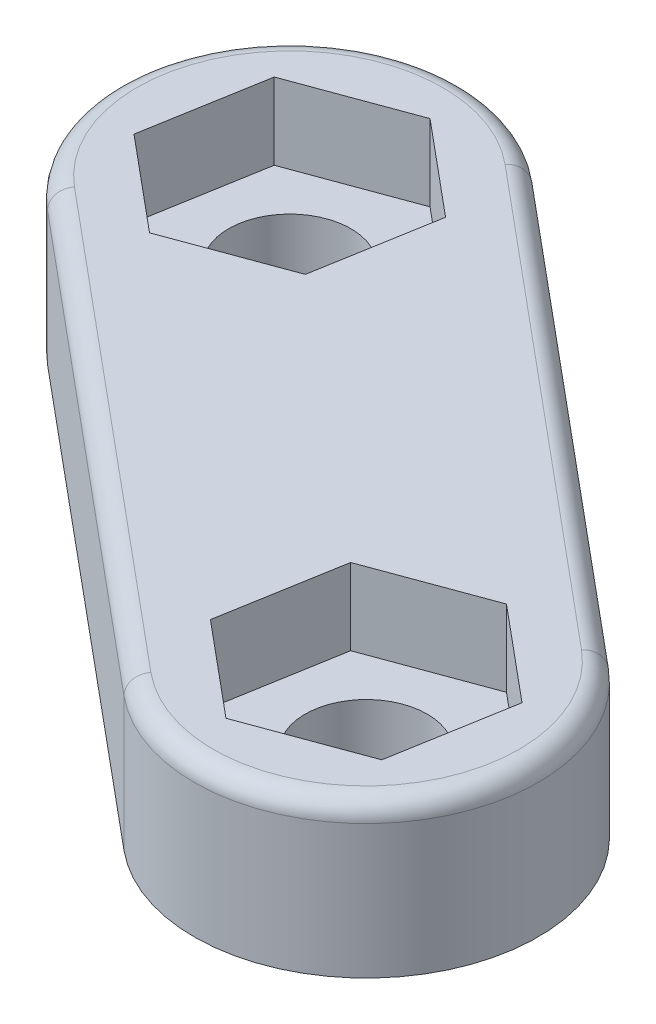
from build123d import *

# Parameters (mm, degrees)
BOSS_EXTRUDE1_DEPTH = 4
CUT_EXTRUDE1_DEPTH  = 2
FILLET1_R           = 0.5


with BuildPart() as part:
    # Sketch1 → Boss-Extrude1 (new body)
    with BuildSketch(Plane(origin=(0, 0, 0), x_dir=(1, 0, 0), z_dir=(0, 1, 0))):
        with BuildLine():
            ThreePointArc((-3.119170202, 8.456995758), (-9.456995758, 7.880829798), (-8.880829798, 1.543004242))
            ThreePointArc((-8.880829798, 1.543004242), (-7.531913687, 0.7687779), (-6, 0.5))
            Line((-6, 0.5), (-6, 3.4))
            ThreePointArc((-6, 3.4), (-7.13137085, 6.13137085), (-4.4, 5))
            Line((-4.4, 5), (-1.5, 5))
            ThreePointArc((-1.5, 5), (-1.924847604, 6.908699283), (-3.119170202, 8.456995758))
        make_face()
        with BuildLine():
            Line((-6, 3.4), (-6, 0.5))
            ThreePointArc((-6, 0.5), (-2.818019485, 1.818019485), (-1.5, 5))
            Line((-1.5, 5), (-4.4, 5))
            ThreePointArc((-4.4, 5), (-4.86862915, 3.86862915), (-6, 3.4))
        make_face()
        with BuildLine():
            Line((-6, 0.5), (-6, -0.857687257))
            Line((-6, -0.857687257), (-1.029224708, -5))
            Line((-1.029224708, -5), (1.5, -5))
            ThreePointArc((1.5, -5), (2.818019485, -1.818019485), (6, -0.5))
            Line((6, -0.5), (6, 0.857687257))
            Line((6, 0.857687257), (1.029224708, 5))
            Line((1.029224708, 5), (-1.5, 5))
            ThreePointArc((-1.5, 5), (-2.818019485, 1.818019485), (-6, 0.5))
        make_face()
        with BuildLine():
            ThreePointArc((1.5, -5), (1.924847604, -6.908699283), (3.119170202, -8.456995758))
            ThreePointArc((3.119170202, -8.456995758), (7.908699283, -9.075152396), (10.5, -5))
            ThreePointArc((10.5, -5), (10.075152396, -3.091300717), (8.880829798, -1.543004242))
            ThreePointArc((8.880829798, -1.543004242), (7.531913687, -0.7687779), (6, -0.5))
            Line((6, -0.5), (6, -3.4))
            ThreePointArc((6, -3.4), (7.13137085, -3.86862915), (7.6, -5))
            ThreePointArc((7.6, -5), (6, -6.6), (4.4, -5))
            Line((4.4, -5), (1.5, -5))
        make_face()
        with BuildLine():
            ThreePointArc((6, -0.5), (2.818019485, -1.818019485), (1.5, -5))
            Line((1.5, -5), (4.4, -5))
            ThreePointArc((4.4, -5), (4.86862915, -3.86862915), (6, -3.4))
            Line((6, -3.4), (6, -0.5))
        make_face()
        with BuildLine():
            Line((1.5, -5), (-1.029224708, -5))
            Line((-1.029224708, -5), (3.119170202, -8.456995758))
            ThreePointArc((3.119170202, -8.456995758), (1.924847604, -6.908699283), (1.5, -5))
        make_face()
        with BuildLine():
            ThreePointArc((-6, 0.5), (-7.531913687, 0.7687779), (-8.880829798, 1.543004242))
            Line((-8.880829798, 1.543004242), (-6, -0.857687257))
            Line((-6, -0.857687257), (-6, 0.5))
        make_face()
        with BuildLine():
            Line((8.880829798, -1.543004242), (6, 0.857687257))
            Line((6, 0.857687257), (6, -0.5))
            ThreePointArc((6, -0.5), (7.531913687, -0.7687779), (8.880829798, -1.543004242))
        make_face()
        with BuildLine():
            Line((1.029224708, 5), (-3.119170202, 8.456995758))
            ThreePointArc((-3.119170202, 8.456995758), (-1.924847604, 6.908699283), (-1.5, 5))
            Line((-1.5, 5), (1.029224708, 5))
        make_face()
    extrude(amount=BOSS_EXTRUDE1_DEPTH)

    # Sketch2 → Cut-Extrude1 (cut)
    with BuildSketch(Plane(origin=(0, 4, 0), x_dir=(1, 0, 0), z_dir=(0, 1, 0))):
        Polygon((-8.439430194, 7.032858495), (-8.980222196, 3.903820729), (-6.540792002, 1.870962234), (-3.560569806, 2.967141505), (-3.019777804, 6.096179271), (-5.459207998, 8.129037766), align=None)
        Polygon((5.459207998, -8.129037766), (3.019777804, -6.096179271), (3.560569806, -2.967141505), (6.540792002, -1.870962234), (8.980222196, -3.903820729), (8.439430194, -7.032858495), align=None)
    extrude(amount=-CUT_EXTRUDE1_DEPTH, mode=Mode.SUBTRACT)

    # Fillet1
    fillet1_edges = [part.edges().sort_by_distance(p)[0] for p in [
        (-2.880829798, 4, 3.456995758),
        (9.456995758, 4, 7.880829798),
        (2.880829798, 4, -3.456995758),
        (-9.456995758, 4, -7.880829798),
    ]]
    fillet(fillet1_edges, radius=FILLET1_R)


solid = part.part
